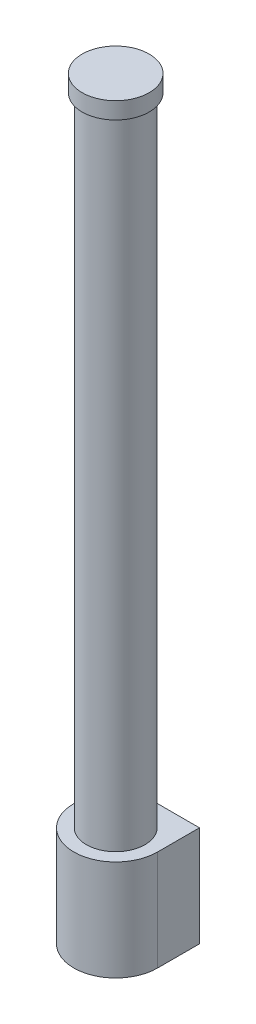
from build123d import *

# Parameters (mm, degrees)
SKETCH1_R           = 22.225
BOSS_EXTRUDE1_DEPTH = 482.6
SKETCH2_R           = 25.4
BOSS_EXTRUDE2_DEPTH = 12.7
BOSS_EXTRUDE3_DEPTH = 76.2


with BuildPart() as part:
    # Sketch1 → Boss-Extrude1 (new body)
    with BuildSketch(Plane(origin=(0, 0, 0), x_dir=(1, 0, 0), z_dir=(0, 1, 0))):
        Circle(SKETCH1_R)
    extrude(amount=BOSS_EXTRUDE1_DEPTH)

    # Sketch2 → Boss-Extrude2 (add)
    with BuildSketch(Plane(origin=(0, 482.6, 0), x_dir=(1, 0, 0), z_dir=(0, 1, 0))):
        Circle(SKETCH2_R)
    extrude(amount=BOSS_EXTRUDE2_DEPTH)

    # Sketch3 → Boss-Extrude3 (add)
    with BuildSketch(Plane.XZ):
        with BuildLine():
            Line((-31.75, 0), (-31.75, -31.75))
            Line((-31.75, -31.75), (31.75, -31.75))
            Line((31.75, -31.75), (31.75, 0))
            ThreePointArc((31.75, 0), (0, 31.75), (-31.75, 0))
        make_face()
    extrude(amount=BOSS_EXTRUDE3_DEPTH)


solid = part.part
